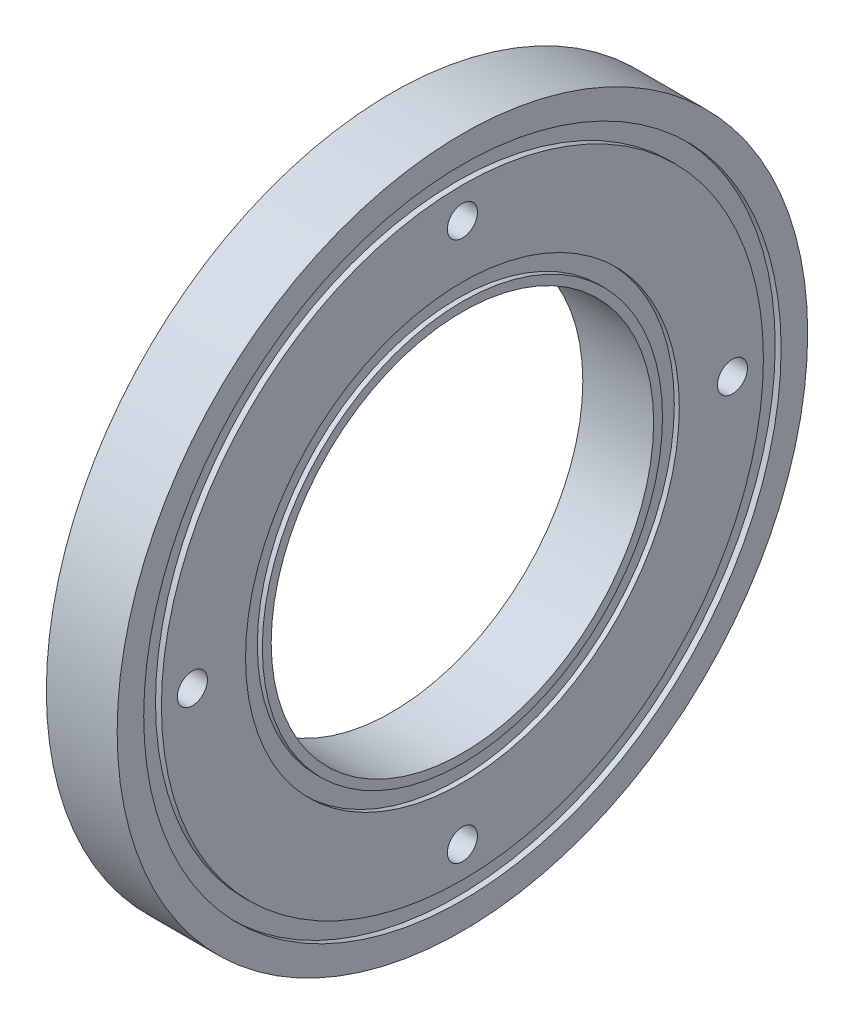
from build123d import *

# Parameters (mm, degrees)
M3_CLEARANCE_HOLE1_D     = 3.4
M3_CLEARANCE_HOLE1_DEPTH = 8
M3_CLEARANCE_HOLE1_TIP   = 1.021463052


with BuildPart() as part:
    # Sketch1 → Revolve17 (revolve)
    with BuildSketch(Plane.XY):
        Polygon((20.481671209, 24.5), (21.047671209, 24.5), (21.047671209, 34), (20.380671209, 34), (20.380671209, 36), (21.047671209, 36), (21.047671209, 39), (13.047671209, 39), (13.047671209, 36), (13.714671209, 36), (13.714671209, 34), (13.047671209, 34), (13.047671209, 24.5), (13.613671209, 24.5), (13.613671209, 22.6), (13.047671209, 22.6), (13.047671209, 21.6), (21.047671209, 21.6), (21.047671209, 22.6), (20.481671209, 22.6), align=None)
    revolve(axis=Axis((-801.920554309, 0, 0), (1, 0, 0)))

    # M3 Clearance Hole1
    with Locations(Plane.ZY.offset(-13.047671209)):
        with Locations((0, -30.5), (0, 30.5), (30.5, 0), (-30.5, 0)):
            Hole(M3_CLEARANCE_HOLE1_D / 2, depth=M3_CLEARANCE_HOLE1_DEPTH)
            with Locations((0, 0, -(M3_CLEARANCE_HOLE1_DEPTH + M3_CLEARANCE_HOLE1_TIP / 2))):  # 118° drill point
                Cone(0, M3_CLEARANCE_HOLE1_D / 2, M3_CLEARANCE_HOLE1_TIP, mode=Mode.SUBTRACT)


solid = part.part
